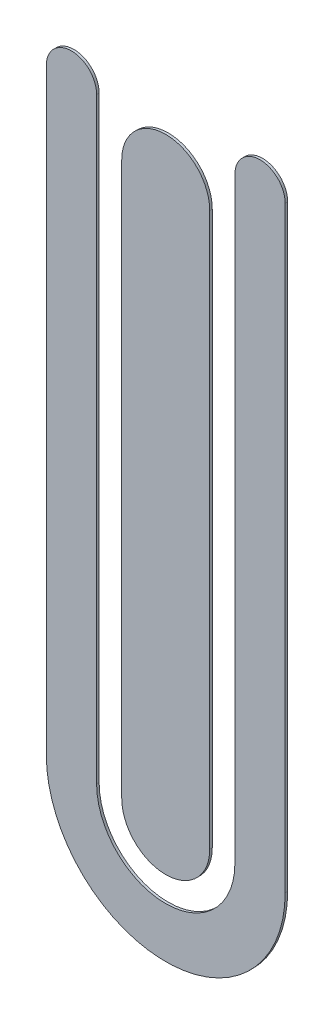
from build123d import *

# Parameters (mm, degrees)
Y_KSEKLIK_EKSTR_ZYON1_DEPTH   = 0.2
Y_KSEKLIK_EKSTR_ZYON1_2_DEPTH = 0.2


with BuildPart() as part:
    # Çizim1 → Yükseklik-Ekstrüzyon1 (new body)
    with BuildSketch(Plane.XY):
        with BuildLine():
            Line((3.5, 22), (3.5, -22))
            ThreePointArc((3.5, -22), (0, -25.5), (-3.5, -22))
            Line((-3.5, -22), (-3.5, 22))
            ThreePointArc((-3.5, 22), (0, 25.5), (3.5, 22))
        make_face()
    extrude(amount=Y_KSEKLIK_EKSTR_ZYON1_DEPTH)


with BuildPart() as body_2:
    # Çizim1 → Y_kseklik-Ekstr_zyon1 2 (new body)
    with BuildSketch(Plane.XY):
        with BuildLine():
            Line((9.5, 25.5), (9.5, -22))
            ThreePointArc((9.5, -22), (0, -31.5), (-9.5, -22))
            Line((-9.5, -22), (-9.5, 25.5))
            ThreePointArc((-9.5, 25.5), (-7.5, 27.5), (-5.5, 25.5))
            Line((-5.5, 25.5), (-5.5, -22))
            ThreePointArc((-5.5, -22), (0, -27.5), (5.5, -22))
            Line((5.5, -22), (5.5, 25.5))
            ThreePointArc((5.5, 25.5), (7.5, 27.5), (9.5, 25.5))
        make_face()
    extrude(amount=Y_KSEKLIK_EKSTR_ZYON1_2_DEPTH)


solid = Compound([part.part, body_2.part])
